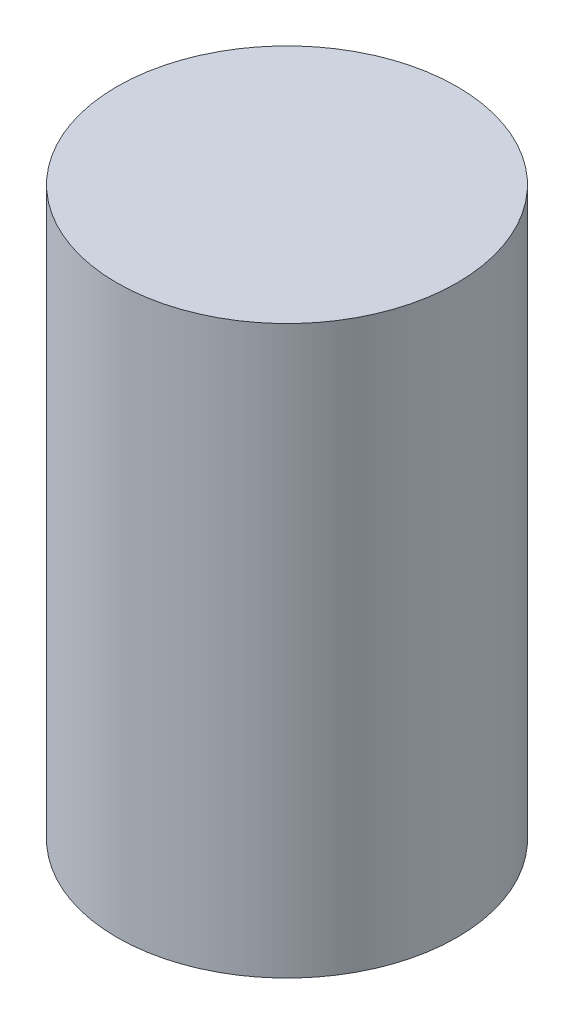
from build123d import *

# Parameters (mm, degrees)
SKETCH1_R           = 38.1
BOSS_EXTRUDE1_DEPTH = 127


with BuildPart() as part:
    # Sketch1 → Boss-Extrude1 (new body)
    with BuildSketch(Plane(origin=(0, 0, 0), x_dir=(1, 0, 0), z_dir=(0, 1, 0))):
        Circle(SKETCH1_R)
    extrude(amount=BOSS_EXTRUDE1_DEPTH)


solid = part.part
